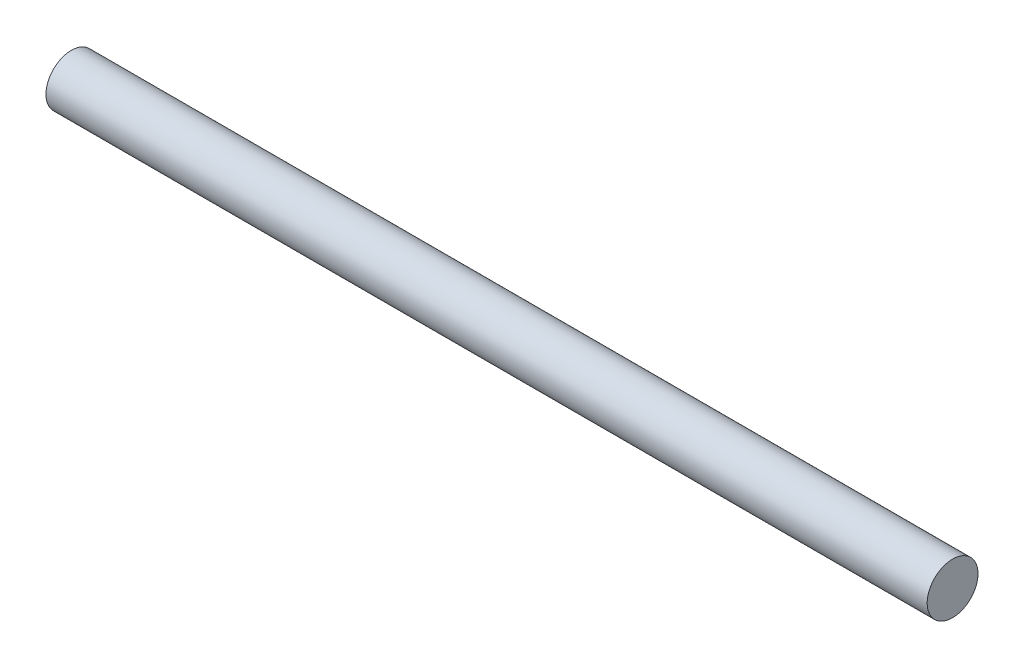
from build123d import *

# Parameters (mm, degrees)
SKETCH1_R           = 0.75
BOSS_EXTRUDE1_DEPTH = 26


with BuildPart() as part:
    # Sketch1 → Boss-Extrude1 (new body)
    with BuildSketch(Plane(origin=(0, 0, 0), x_dir=(0, 0, -1), z_dir=(1, 0, 0))):
        with Locations((-22.694500217, 11.062992171)):
            Circle(SKETCH1_R)
    extrude(amount=BOSS_EXTRUDE1_DEPTH)


solid = part.part
